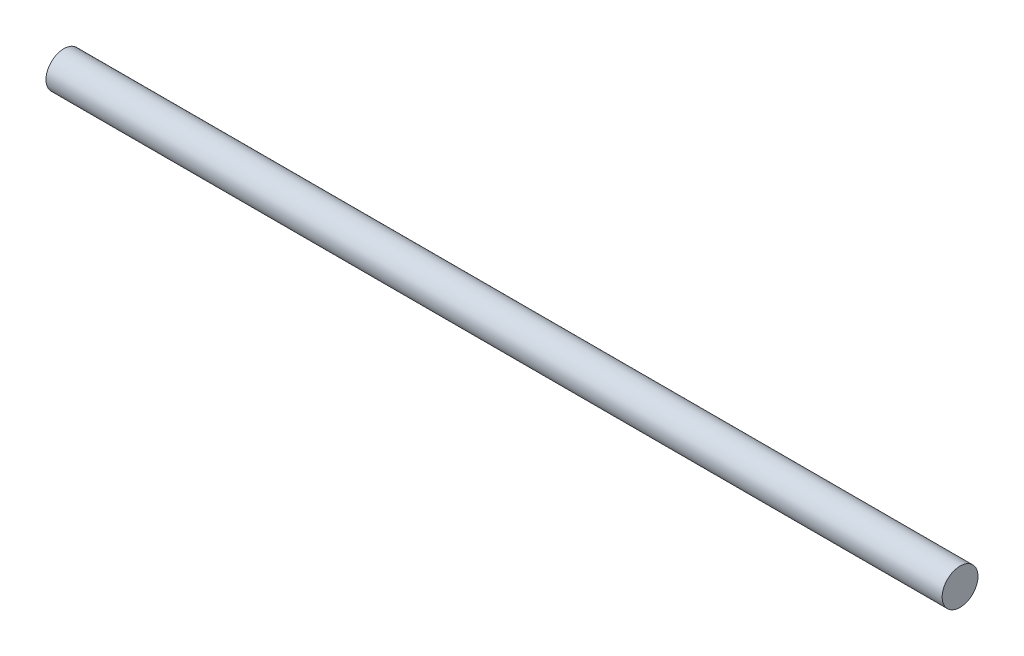
from build123d import *

# Parameters (mm, degrees)
SKETCH1_R           = 1.5875
BOSS_EXTRUDE1_DEPTH = 39.6875


with BuildPart() as part:
    # Sketch1 → Boss-Extrude1 (new body, symmetric)
    with BuildSketch(Plane(origin=(0, 0, 0), x_dir=(0, 0, -1), z_dir=(1, 0, 0))):
        Circle(SKETCH1_R)
    extrude(amount=BOSS_EXTRUDE1_DEPTH, both=True)


solid = part.part
